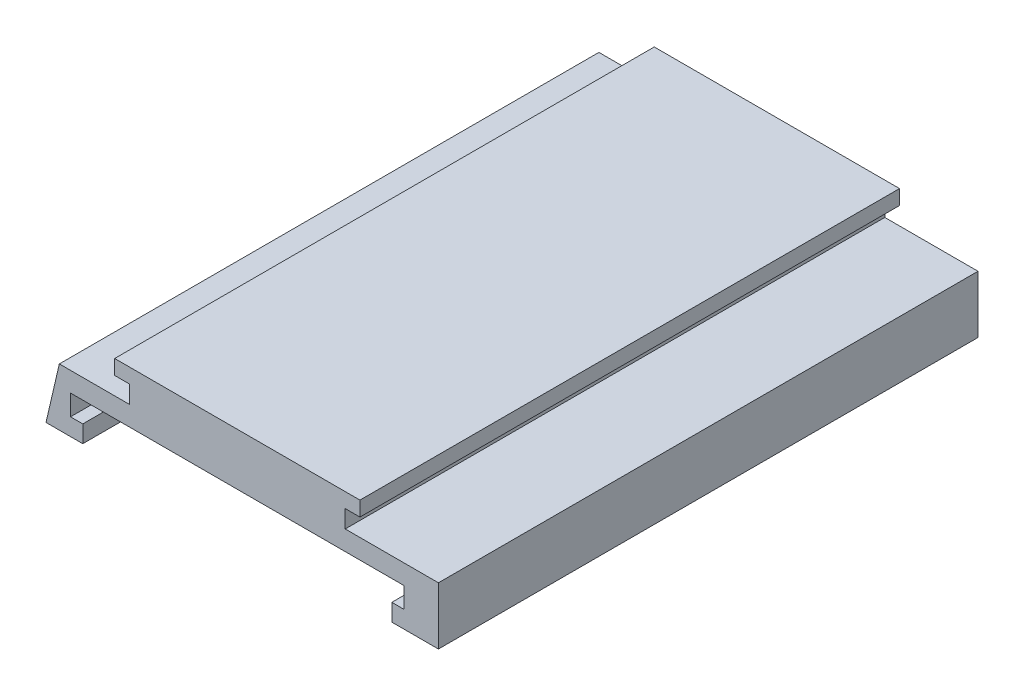
from build123d import *

# Parameters (mm, degrees)
BOSS_EXTRUDE1_DEPTH = 55
CUT_EXTRUDE2_REACH  = 57


with BuildPart() as part:
    # Sketch2 → Boss-Extrude1 (new body)
    with BuildSketch(Plane.XY):
        Polygon((0, 0), (0, 5.85), (9.5, 5.85), (9.5, 7.65), (8, 7.65), (8, 9.15), (33, 9.15), (33, 7.65), (31.5, 7.65), (31.5, 5.85), (41, 5.85), (41, 0), (36.25, 0), (36.25, 1.75), (37.5, 1.75), (37.5, 3.85), (3.5, 3.85), (3.5, 1.75), (4.75, 1.75), (4.75, 0), align=None)
    extrude(amount=BOSS_EXTRUDE1_DEPTH)

    # Sketch3 → Cut-Extrude2 (cut, up to next)
    with BuildSketch(Plane.XY.offset(55), mode=Mode.PRIVATE) as cut_extrude2_sk1:
        Polygon((1, 0), (0, 0), (0, 5.85), (2.358395181, 5.85), align=None)
    cut_extrude2_tool1 = extrude(cut_extrude2_sk1.sketch, amount=-CUT_EXTRUDE2_REACH, mode=Mode.PRIVATE) & part.part
    add(cut_extrude2_tool1.solids().sort_by_distance((0.885385, 3.319366, 55))[0], mode=Mode.SUBTRACT)


solid = part.part
